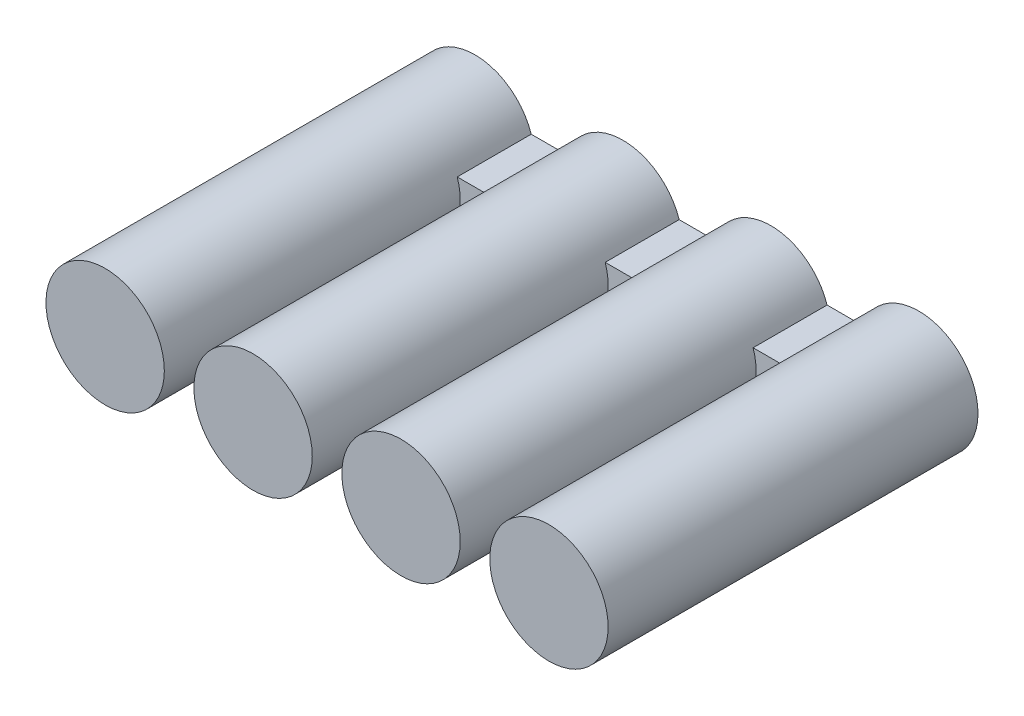
from build123d import *

# Parameters (mm, degrees)
ESBO_O1_R                  = 0.8
RESSALTO_EXTRUS_O1_DEPTH   = 5
RESSALTO_EXTRUS_O1_2_DEPTH = 5
RESSALTO_EXTRUS_O1_3_DEPTH = 5
RESSALTO_EXTRUS_O1_4_DEPTH = 5
ESBO_O2_R                  = 0.8
ESBO_O2_W                  = 5
ESBO_O2_H                  = 0.5
RESSALTO_EXTRUS_O2_DEPTH   = 1


with BuildPart() as part:
    # Esboço1 → Ressalto-extrusão1 (new body)
    with BuildSketch(Plane.XY):
        with Locations((-3.502077011, 1.3792577)):
            Circle(ESBO_O1_R)
    extrude(amount=RESSALTO_EXTRUS_O1_DEPTH)



with BuildPart() as body_2:
    # Esboço1 → Ressalto-extrus_o1 2 (new body)
    with BuildSketch(Plane.XY):
        with Locations((-1.502077011, 1.3792577)):
            Circle(ESBO_O1_R)
    extrude(amount=RESSALTO_EXTRUS_O1_2_DEPTH)


with BuildPart() as body_3:
    # Esboço1 → Ressalto-extrus_o1 3 (new body)
    with BuildSketch(Plane.XY):
        with Locations((0.497922989, 1.3792577)):
            Circle(ESBO_O1_R)
    extrude(amount=RESSALTO_EXTRUS_O1_3_DEPTH)


with BuildPart() as body_4:
    # Esboço1 → Ressalto-extrus_o1 4 (new body)
    with BuildSketch(Plane.XY):
        with Locations((2.497922989, 1.3792577)):
            Circle(ESBO_O1_R)
    extrude(amount=RESSALTO_EXTRUS_O1_4_DEPTH)


with BuildPart() as part_1:
    add(part.part)

    add(body_2.part)  # Ressalto-extrusão2 merges body 2

    add(body_3.part)  # Ressalto-extrusão2 merges body 3

    add(body_4.part)  # Ressalto-extrusão2 merges body 4
    # Esboço2 → Ressalto-extrusão2 (add)
    with BuildSketch(Plane(origin=(0, 0, 0), x_dir=(-1, 0, 0), z_dir=(0, 0, -1))):
        with Locations((-2.497922989, 1.3792577)):
            Circle(ESBO_O2_R)
        with Locations((3.502077011, 1.3792577)):
            Circle(ESBO_O2_R)
        with Locations((0.502077011, 1.3792577)):
            Rectangle(ESBO_O2_W, ESBO_O2_H)
    extrude(amount=-RESSALTO_EXTRUS_O2_DEPTH)


solid = part_1.part
